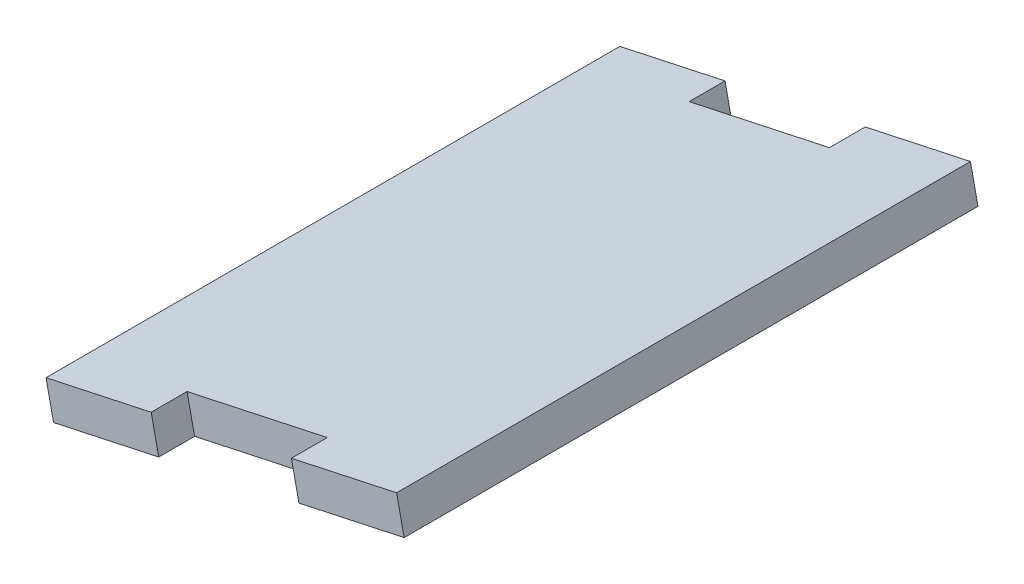
from build123d import *

# Parameters (mm, degrees)
BOSS_EXTRUDE1_DEPTH = 50.8
SKETCH2_W           = 12.7
SKETCH2_H           = 3.175
CUT_EXTRUDE1_DEPTH  = 3.175


with BuildPart() as part:
    # Sketch1 → Boss-Extrude1 (new body)
    with BuildSketch(Plane.XY):
        Polygon((39.563966172, 294.491722579), (40.233488411, 291.388117421), (71.269539981, 298.083339818), (70.600017742, 301.186944975), align=None)
    extrude(amount=-BOSS_EXTRUDE1_DEPTH)

    # Sketch2 → Cut-Extrude1 (cut)
    with BuildSketch(Plane(origin=(-58.944661512, 273.241043546, 0), x_dir=(0.977513435, 0.210873146, 0), z_dir=(-0.210873146, 0.977513435, 0))):
        with Locations((116.649704601, 49.2125)):
            Rectangle(SKETCH2_W, SKETCH2_H)
        with Locations((116.649704601, 1.5875)):
            Rectangle(SKETCH2_W, SKETCH2_H)
    extrude(amount=-CUT_EXTRUDE1_DEPTH, mode=Mode.SUBTRACT)


solid = part.part
